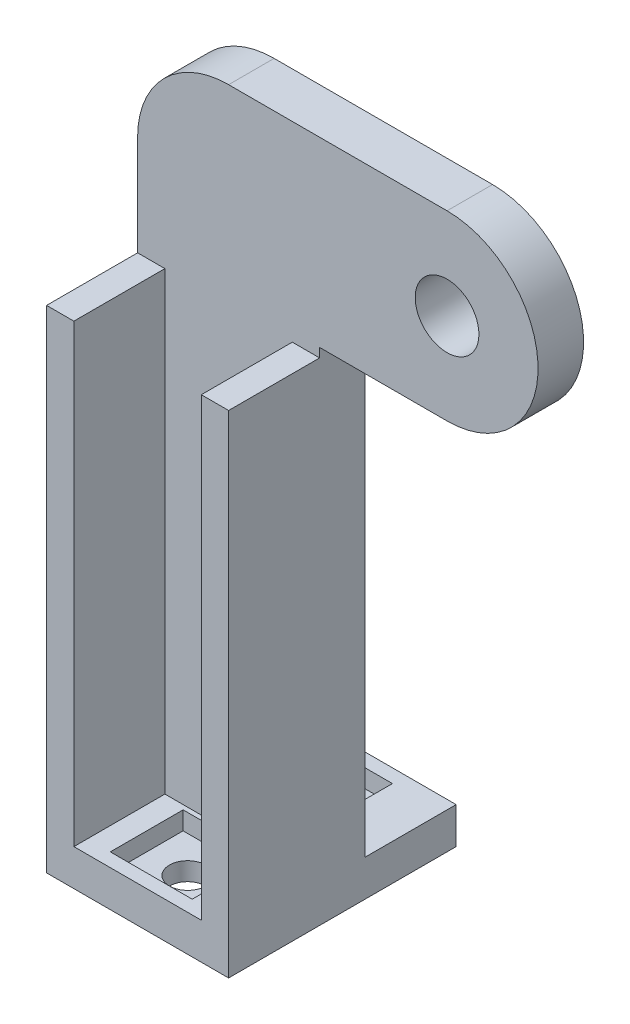
from build123d import *

# Parameters (mm, degrees)
SKETCH1_R          = 1.75
AXLEHOLDER_DEPTH   = 2.5
SKETCH1_3_W        = 10
SKETCH1_3_H        = 2
BASE_DEPTH         = 7.5
BASE_DEPTH_BACK    = 5
SKETCH2_R          = 1
BOLTHOLES_DEPTH    = 3
SKETCH3_W          = 4.5
SKETCH3_H          = 4
NUTSLOTS_DEPTH     = 1
SKETCH4_W          = 1.5
SKETCH4_H          = 5
STIFFENERRIB_DEPTH = 25


with BuildPart() as part:
    # Sketch1 → AxleHolder (new body)
    with BuildSketch(Plane.XY):
        with BuildLine():
            Line((-5, 0), (5, 0))
            Line((5, 0), (5, 27.5))
            Line((5, 27.5), (12, 27.5))
            ThreePointArc((12, 27.5), (17, 32.5), (12, 37.5))
            Line((12, 37.5), (0, 37.5))
            ThreePointArc((0, 37.5), (-3.535533906, 36.035533906), (-5, 32.5))
            Line((-5, 32.5), (-5, 0))
        make_face()
        with Locations((12, 32.5)):
            Circle(SKETCH1_R, mode=Mode.SUBTRACT)
    extrude(amount=AXLEHOLDER_DEPTH)

    # Sketch1_3 → Base (add, two sides)
    with BuildSketch(Plane.XY) as base_sk:
        with Locations((0, 1)):
            Rectangle(SKETCH1_3_W, SKETCH1_3_H)
    extrude(amount=BASE_DEPTH)
    extrude(base_sk.sketch, amount=-BASE_DEPTH_BACK)

    # Sketch2 → BoltHoles (cut, through all)
    with BuildSketch(Plane(origin=(0, 2, 0), x_dir=(1, 0, 0), z_dir=(0, 1, 0))):
        with Locations((0, 2.25)):
            Circle(SKETCH2_R)
        with Locations((0, -4.75)):
            Circle(SKETCH2_R)
    extrude(amount=-BOLTHOLES_DEPTH, mode=Mode.SUBTRACT)

    # Sketch3 → NutSlots (cut)
    with BuildSketch(Plane(origin=(0, 2, 0), x_dir=(1, 0, 0), z_dir=(0, 1, 0))):
        with Locations((0, -4.75)):
            Rectangle(SKETCH3_W, SKETCH3_H)
        with Locations((0, 2.25)):
            Rectangle(SKETCH3_W, SKETCH3_H)
    extrude(amount=-NUTSLOTS_DEPTH, mode=Mode.SUBTRACT)

    # Sketch4 → StiffenerRib (add)
    with BuildSketch(Plane(origin=(0, 2, 0), x_dir=(1, 0, 0), z_dir=(0, 1, 0))):
        with Locations((-4.25, -5)):
            Rectangle(SKETCH4_W, SKETCH4_H)
    stiffenerrib = extrude(amount=STIFFENERRIB_DEPTH)

    # StiffenerRib2: StiffenerRib across plane
    add(stiffenerrib.mirror(Plane(origin=(0, 0, 0), x_dir=(0, 0, 1), z_dir=(1, 0, 0))))


solid = part.part
